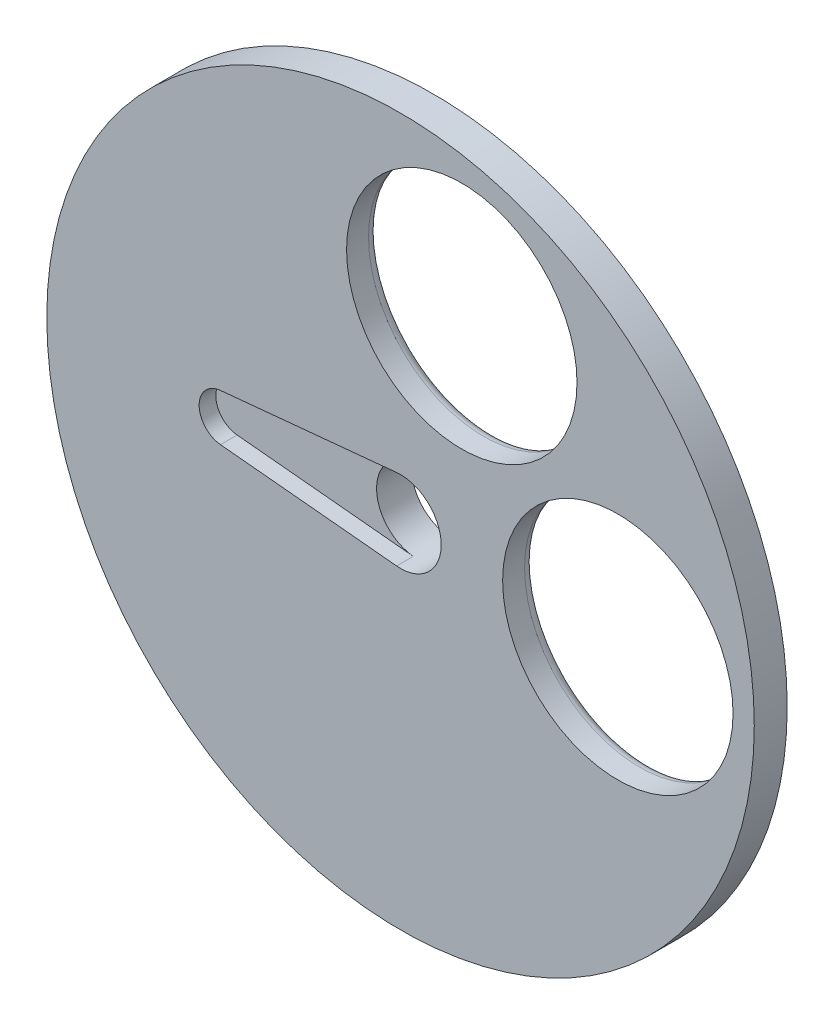
from build123d import *

# Parameters (mm, degrees)
SKETCH_1_R        = 32.236701024
SKETCH_1_R_2      = 10.5
EXTRUDE_1_DEPTH   = 1.52
SKETCH_2_R        = 32.236701024
SKETCH_2_R_2      = 10.5
SKETCH_2_R_3      = 3.705
EXTRUDE_2_DEPTH   = 1.48
FILLET_1_R        = 1
SKETCH_3_R        = 5.705
SKETCH_3_R_2      = 3.705
EXTRUDE_1_2_DEPTH = 1.7


with BuildPart() as part:
    # 草图1 → Extrude 1 (new body)
    with BuildSketch(Plane.XY):
        Circle(SKETCH_1_R)
        with Locations((5.58185679, 19)):
            Circle(SKETCH_1_R_2, mode=Mode.SUBTRACT)
        with Locations((19.802957487, 0)):
            Circle(SKETCH_1_R_2, mode=Mode.SUBTRACT)
        with BuildLine():
            Line((-0.355524529, 3.687902833), (-16.411309781, 2.140078567))
            ThreePointArc((-16.411309781, 2.140078567), (-18.355, 0), (-16.411309781, -2.140078567))
            Line((-16.411309781, -2.140078567), (-0.355524529, -3.687902833))
            ThreePointArc((-0.355524529, -3.687902833), (3.705, 0), (-0.355524529, 3.687902833))
        make_face(mode=Mode.SUBTRACT)
    extrude(amount=-EXTRUDE_1_DEPTH)

    # 草图2 → 凸台-拉伸2 (add)
    with BuildSketch(Plane(origin=(0, 0, -1.52), x_dir=(-1, 0, 0), z_dir=(0, 0, -1))):
        Circle(SKETCH_2_R)
        with Locations((-5.58185679, 19)):
            Circle(SKETCH_2_R_2, mode=Mode.SUBTRACT)
        with Locations((-19.802957487, 0)):
            Circle(SKETCH_2_R_2, mode=Mode.SUBTRACT)
        Circle(SKETCH_2_R_3, mode=Mode.SUBTRACT)
    extrude(amount=EXTRUDE_2_DEPTH)

    # 圆角1
    fillet_1_edges = [part.edges().sort_by_distance(p)[0] for p in [
        (30.302957487, 0, -3),
        (16.08185679, 19, -3),
    ]]
    fillet(fillet_1_edges, radius=FILLET_1_R)

    # 草图3 → Extrude 1 2 (add)
    with BuildSketch(Plane(origin=(0, 0, -3), x_dir=(-1, 0, 0), z_dir=(0, 0, -1))):
        Circle(SKETCH_3_R)
        Circle(SKETCH_3_R_2, mode=Mode.SUBTRACT)
    extrude(amount=EXTRUDE_1_2_DEPTH)


solid = part.part
